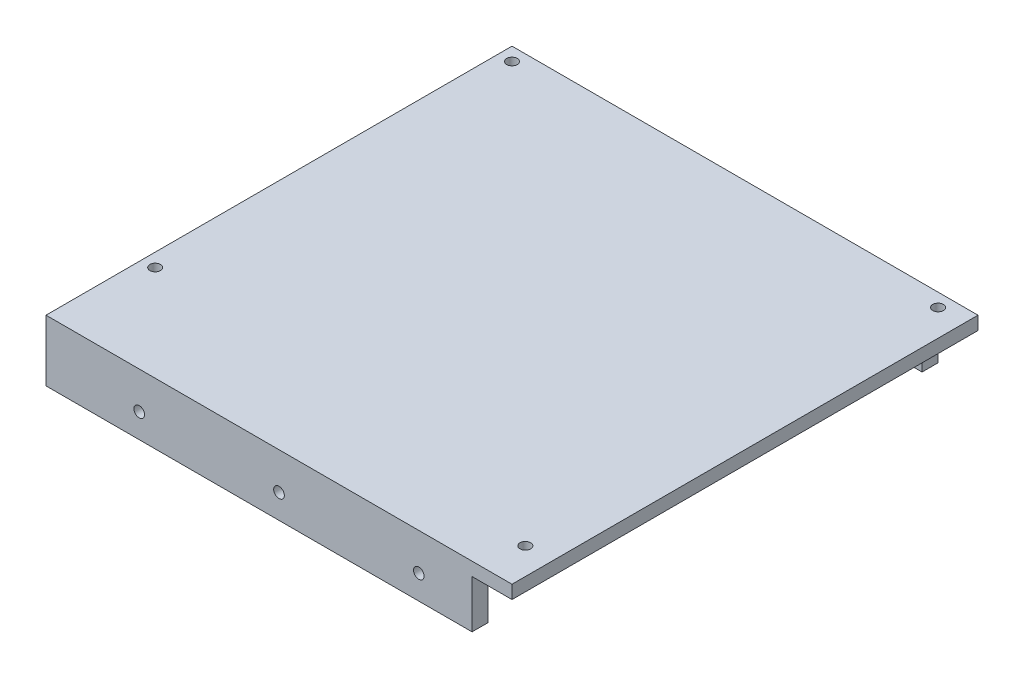
from build123d import *

# Parameters (mm, degrees)
SKETCH1_W               = 175
SKETCH1_H               = 175
BOSS_EXTRUDE1_DEPTH     = 5
SKETCH2_R               = 2
CUT_EXTRUDE1_DEPTH      = 5
SKETCH3_W               = 160
SKETCH3_H               = 6
SKETCH3_W_2             = 145
BOSS_EXTRUDE3_DEPTH     = 18
SKETCH4_R               = 2
CUT_EXTRUDE2_DEPTH      = 1
CUT_EXTRUDE2_DEPTH_BACK = 176
SKETCH5_R               = 5
CUT_EXTRUDE3_DEPTH      = 2.5


with BuildPart() as part:
    # Sketch1 → Boss-Extrude1 (new body)
    with BuildSketch(Plane(origin=(0, 0, 0), x_dir=(1, 0, 0), z_dir=(0, 1, 0))):
        with Locations((-24.045801527, -27.385496183)):
            Rectangle(SKETCH1_W, SKETCH1_H)
    extrude(amount=BOSS_EXTRUDE1_DEPTH)

    # Sketch2 → Cut-Extrude1 (cut)
    with BuildSketch(Plane(origin=(0, 5, 0), x_dir=(1, 0, 0), z_dir=(0, 1, 0))):
        with Locations((-106.545801527, 55.114503817)):
            Circle(SKETCH2_R)
        with Locations((53.454198473, 55.114503817)):
            Circle(SKETCH2_R)
        with Locations((53.454198473, -99.885496183)):
            Circle(SKETCH2_R)
        with Locations((-106.545801527, -78.885496183)):
            Circle(SKETCH2_R)
    extrude(amount=-CUT_EXTRUDE1_DEPTH, mode=Mode.SUBTRACT)

    # Sketch3 → Boss-Extrude3 (add)
    with BuildSketch(Plane.XZ):
        with Locations((-31.545801527, 111.885496183)):
            Rectangle(SKETCH3_W, SKETCH3_H)
        with Locations((-24.045801527, -57.114503817)):
            Rectangle(SKETCH3_W_2, SKETCH3_H)
    extrude(amount=BOSS_EXTRUDE3_DEPTH)

    # Sketch4 → Cut-Extrude2 (cut, two sides)
    with BuildSketch(Plane(origin=(0, 0, -60.114503817), x_dir=(-1, 0, 0), z_dir=(0, 0, -1))) as cut_extrude2_sk:
        with Locations((-28.454198473, -8.900832872)):
            Circle(SKETCH4_R)
        with Locations((24.045801527, -8.900832872)):
            Circle(SKETCH4_R)
        with Locations((76.545801527, -8.900832872)):
            Circle(SKETCH4_R)
    extrude(amount=CUT_EXTRUDE2_DEPTH, mode=Mode.SUBTRACT)
    extrude(cut_extrude2_sk.sketch, amount=-CUT_EXTRUDE2_DEPTH_BACK, mode=Mode.SUBTRACT)

    # Sketch5 → Cut-Extrude3 (cut)
    with BuildSketch(Plane(origin=(0, 0, -60.114503817), x_dir=(-1, 0, 0), z_dir=(0, 0, -1))):
        with Locations((-28.454198473, -8.900832872)):
            Circle(SKETCH5_R)
        with Locations((24.045801527, -8.900832872)):
            Circle(SKETCH5_R)
        with Locations((76.545801527, -8.900832872)):
            Circle(SKETCH5_R)
    extrude(amount=-CUT_EXTRUDE3_DEPTH, mode=Mode.SUBTRACT)


solid = part.part
